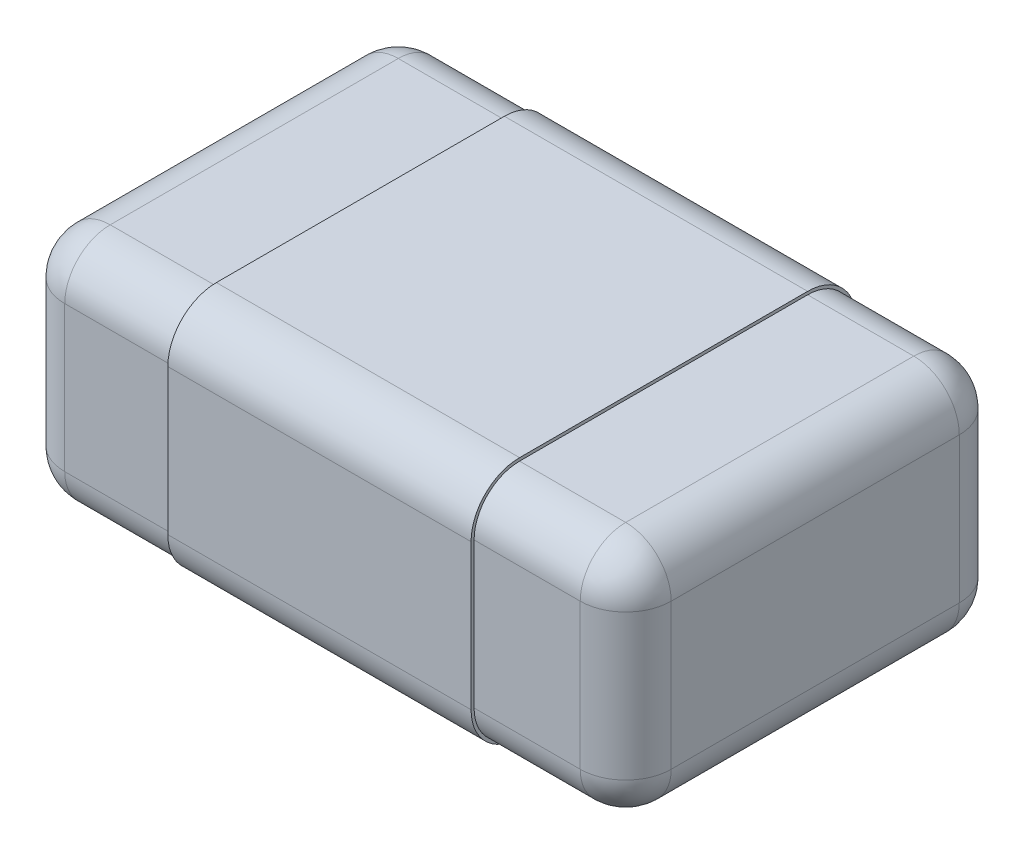
from build123d import *

# Parameters (mm, degrees)
ESBO_O1_W                     = 2
ESBO_O1_H                     = 1.25
RESSALTO_EXTRUS_O1_DEPTH      = 0.78
FILETE1_R                     = 0.15
RESSALTO_EXTRUS_O4_DEPTH      = 0.5
RESSALTO_EXTRUS_O4_DEPTH_BACK = 0.5
RESSALTO_EXTRUS_O5_DEPTH      = 0.02


with BuildPart() as part:
    # Esboço1 → Ressalto-extrusão1 (new body)
    with BuildSketch(Plane(origin=(0, 0, 0), x_dir=(1, 0, 0), z_dir=(0, 1, 0))):
        Rectangle(ESBO_O1_W, ESBO_O1_H)
    extrude(amount=-RESSALTO_EXTRUS_O1_DEPTH)

    # Filete1
    filete1_edges = [part.edges().sort_by_distance(p)[0] for p in [
        (1, -0.78, 0),
        (0, -0.78, -0.625),
        (-1, -0.78, 0),
        (0, 0, -0.625),
        (1, 0, 0),
        (0, 0, 0.625),
        (-1, 0, 0),
        (0, -0.78, 0.625),
        (-1, -0.39, -0.625),
        (1, -0.39, -0.625),
        (1, -0.39, 0.625),
        (-1, -0.39, 0.625),
    ]]
    fillet(filete1_edges, radius=FILETE1_R)

    # Esboço4 → Ressalto-extrusão4 (add, two sides)
    with BuildSketch(Plane(origin=(0, 0, 0), x_dir=(0, 0, -1), z_dir=(1, 0, 0))) as ressalto_extrus_o4_sk:
        with BuildLine():
            Line((0.635, -0.63), (0.635, -0.15))
            ThreePointArc((0.635, -0.15), (0.588137085, -0.036862915), (0.475, 0.01))
            Line((0.475, 0.01), (-0.475, 0.01))
            ThreePointArc((-0.475, 0.01), (-0.588137085, -0.036862915), (-0.635, -0.15))
            Line((-0.635, -0.15), (-0.635, -0.63))
            ThreePointArc((-0.635, -0.63), (-0.588137085, -0.743137085), (-0.475, -0.79))
            Line((-0.475, -0.79), (0.475, -0.79))
            ThreePointArc((0.475, -0.79), (0.588137085, -0.743137085), (0.635, -0.63))
        make_face()
        with BuildLine():
            Line((0.625, -0.63), (0.625, -0.15))
            ThreePointArc((0.625, -0.15), (0.581066017, -0.043933983), (0.475, 0))
            Line((0.475, 0), (-0.475, 0))
            ThreePointArc((-0.475, 0), (-0.581066017, -0.043933983), (-0.625, -0.15))
            Line((-0.625, -0.15), (-0.625, -0.63))
            ThreePointArc((-0.625, -0.63), (-0.581066017, -0.736066017), (-0.475, -0.78))
            Line((-0.475, -0.78), (0.475, -0.78))
            ThreePointArc((0.475, -0.78), (0.581066017, -0.736066017), (0.625, -0.63))
        make_face(mode=Mode.SUBTRACT)
    extrude(amount=RESSALTO_EXTRUS_O4_DEPTH)
    extrude(ressalto_extrus_o4_sk.sketch, amount=-RESSALTO_EXTRUS_O4_DEPTH_BACK)

    # Esboço2 → Ressalto-extrusão5 (add)
    with BuildSketch(Plane(origin=(0, -0.79, 0), x_dir=(0, 0, 1), z_dir=(0, -1, 0))):
        with BuildLine():
            Line((0.240411447, -0.215189873), (0.240411447, -0.462025316))
            Line((0.240411447, -0.462025316), (0.158330751, -0.462025316))
            add(Edge.make_bspline(
                [(0.158330751, -0.462025316), (0.152214367, -0.456963441), (0.140208237, -0.447027254), (0.12230397, -0.432732049), (0.104986645, -0.419110313), (0.088088852, -0.406373508), (0.071638652, -0.394418598), (0.055729879, -0.383059249), (0.04010761, -0.372628254), (0.02977976, -0.365986606), (0.024727112, -0.362737342)],
                knots=[0, 0, 0, 0, 1.143871494, 2.245357909, 3.300914739, 4.318253735, 5.293884102, 6.230829319, 7.13447631, 8, 8, 8, 8], degree=3))
            add(Edge.make_bspline(
                [(0.024727112, -0.362737342), (0.018467772, -0.358883426), (0.00649251, -0.351510179), (-0.011299949, -0.341907859), (-0.027841839, -0.333863461), (-0.043428254, -0.327364414), (-0.058501424, -0.322335856), (-0.073657737, -0.319037953), (-0.088968207, -0.316848981), (-0.099276497, -0.316586719), (-0.104426369, -0.316455696)],
                knots=[0, 0, 0, 0, 1.267768508, 2.425473269, 3.486024264, 4.439590646, 5.336903618, 6.222592004, 7.112032784, 8, 8, 8, 8], degree=3))
            add(Edge.make_bspline(
                [(-0.104426369, -0.316455696), (-0.109973533, -0.31661856), (-0.120442742, -0.316925935), (-0.135183808, -0.319395248), (-0.147862366, -0.3238687), (-0.158544157, -0.329955464), (-0.16699737, -0.337794162), (-0.172986786, -0.347194623), (-0.176714501, -0.357985485), (-0.177106684, -0.365673027), (-0.177310072, -0.36965981)],
                knots=[0, 0, 0, 0, 1.306909451, 2.466541577, 3.505869428, 4.459795217, 5.344572835, 6.193571478, 7.063180651, 8, 8, 8, 8], degree=3))
            add(Edge.make_bspline(
                [(-0.177310072, -0.36965981), (-0.177088445, -0.373873366), (-0.176649647, -0.382215733), (-0.172906717, -0.394304114), (-0.167362161, -0.405870143), (-0.162961227, -0.413368033), (-0.160696148, -0.417227057)],
                knots=[0, 0, 0, 0, 0.988472559, 1.957064427, 2.948539211, 4, 4, 4, 4], degree=3))
            add(Edge.make_bspline(
                [(-0.160696148, -0.417227057), (-0.158162705, -0.420841831), (-0.153335217, -0.427729798), (-0.14551733, -0.436518088), (-0.138585493, -0.443311015), (-0.134646389, -0.447447152), (-0.133006275, -0.449169304)],
                knots=[0, 0, 0, 0, 1.249878488, 2.381649198, 3.326171657, 4, 4, 4, 4], degree=3))
            Line((-0.133006275, -0.449169304), (-0.133006275, -0.455696203))
            Line((-0.133006275, -0.455696203), (-0.241293458, -0.455696203))
            add(Edge.make_bspline(
                [(-0.241293458, -0.455696203), (-0.243030602, -0.452991868), (-0.246833272, -0.447071984), (-0.251734635, -0.436649009), (-0.256834934, -0.424293195), (-0.26197876, -0.410355035), (-0.266458759, -0.395520181), (-0.269739252, -0.380513709), (-0.271805277, -0.365794466), (-0.272101339, -0.356051915), (-0.272246781, -0.351265823)],
                knots=[0, 0, 0, 0, 0.69970136, 1.531670699, 2.504079761, 3.612943238, 4.767349377, 5.877514774, 6.957315063, 8, 8, 8, 8], degree=3))
            add(Edge.make_bspline(
                [(-0.272246781, -0.351265823), (-0.272145838, -0.346348053), (-0.271949257, -0.336770977), (-0.270052265, -0.322880358), (-0.266883874, -0.309923425), (-0.262513205, -0.297885305), (-0.2570145, -0.286673475), (-0.24997581, -0.276546396), (-0.241814993, -0.267285593), (-0.232475839, -0.258916878), (-0.221906303, -0.251655604), (-0.21043315, -0.245154857), (-0.197820463, -0.239860807), (-0.184283525, -0.23536637), (-0.169658558, -0.232092503), (-0.154107163, -0.2296073), (-0.137518514, -0.228111727), (-0.126119876, -0.227937721), (-0.120249154, -0.227848101)],
                knots=[0, 0, 0, 0, 1.059873424, 2.064042983, 3.015596836, 3.930697506, 4.820695307, 5.699957467, 6.581199529, 7.477193696, 8.396013015, 9.341094634, 10.315416404, 11.340324501, 12.412707035, 13.542640562, 14.734368785, 16, 16, 16, 16], degree=3))
            add(Edge.make_bspline(
                [(-0.120249154, -0.227848101), (-0.112856677, -0.228016187), (-0.098089689, -0.22835195), (-0.076109458, -0.23116239), (-0.054324675, -0.235452453), (-0.032644635, -0.241809914), (-0.010659972, -0.250133389), (0.01194365, -0.260654571), (0.035218138, -0.273724386), (0.050657644, -0.283701701), (0.058647207, -0.288864715)],
                knots=[0, 0, 0, 0, 0.92383478, 1.845424201, 2.765944236, 3.697111989, 4.666093288, 5.70224482, 6.810968485, 8, 8, 8, 8], degree=3))
            add(Edge.make_bspline(
                [(0.058647207, -0.288864715), (0.063540545, -0.292239236), (0.073096713, -0.298829317), (0.086879374, -0.3088528), (0.099855338, -0.318723297), (0.111778424, -0.328382753), (0.122497499, -0.33725099), (0.13166194, -0.344970557), (0.139184524, -0.351253132), (0.143567164, -0.355051598), (0.145474738, -0.356704905)],
                knots=[0, 0, 0, 0, 1.293836837, 2.526725554, 3.709287413, 4.842241028, 5.866627263, 6.737584004, 7.450524958, 8, 8, 8, 8], degree=3))
            Line((0.145474738, -0.356704905), (0.145474738, -0.215189873))
            Line((0.145474738, -0.215189873), (0.240411447, -0.215189873))
        make_face()
        with BuildLine():
            add(Edge.make_bspline(
                [(-0.00988523, 0.120886076), (0.00066438, 0.120777596), (0.021112324, 0.120567332), (0.050770501, 0.119340622), (0.078415824, 0.117074446), (0.10401909, 0.113930641), (0.127675305, 0.11001546), (0.149219582, 0.104722524), (0.168857978, 0.09868919), (0.180855217, 0.093374077), (0.186613979, 0.090822785)],
                knots=[0, 0, 0, 0, 1.264448795, 2.450837183, 3.556883169, 4.58795224, 5.542121969, 6.428511603, 7.245674236, 8, 8, 8, 8], degree=3))
            add(Edge.make_bspline(
                [(0.186613979, 0.090822785), (0.191832724, 0.088116676), (0.201962475, 0.082864032), (0.215475974, 0.073081294), (0.227068062, 0.062211939), (0.236600164, 0.050031826), (0.243987269, 0.036453455), (0.249411672, 0.021580295), (0.252443019, 0.005204892), (0.252855826, -0.006145441), (0.253069675, -0.012025316)],
                knots=[0, 0, 0, 0, 1.083268664, 2.102659247, 3.066213605, 4.006517345, 4.942721993, 5.906487414, 6.915486013, 8, 8, 8, 8], degree=3))
            add(Edge.make_bspline(
                [(0.253069675, -0.012025316), (0.252852783, -0.017871645), (0.252432967, -0.029187831), (0.249431014, -0.045506204), (0.243963122, -0.060330616), (0.236600695, -0.073883764), (0.227031616, -0.0861274), (0.215297585, -0.09703571), (0.201515042, -0.106829225), (0.191236688, -0.112131567), (0.185921732, -0.114873418)],
                knots=[0, 0, 0, 0, 1.07440951, 2.079632991, 3.034098871, 3.966800755, 4.903586396, 5.876505587, 6.901937131, 8, 8, 8, 8], degree=3))
            add(Edge.make_bspline(
                [(0.185921732, -0.114873418), (0.180129026, -0.117422161), (0.168091236, -0.122718691), (0.148460723, -0.128771479), (0.127002925, -0.134018254), (0.103578021, -0.138143353), (0.078175642, -0.141083229), (0.050772622, -0.143405159), (0.021276728, -0.144615824), (0.000927931, -0.144827376), (-0.009588553, -0.144936709)],
                knots=[0, 0, 0, 0, 0.761707614, 1.582900397, 2.469804074, 3.421542703, 4.445391707, 5.54897881, 6.73328501, 8, 8, 8, 8], degree=3))
            add(Edge.make_bspline(
                [(-0.009588553, -0.144936709), (-0.020369762, -0.144887229), (-0.041117875, -0.144792007), (-0.071028581, -0.143333759), (-0.098482372, -0.1412524), (-0.123614463, -0.13823957), (-0.146683241, -0.134109276), (-0.167944168, -0.128750561), (-0.187668818, -0.122481979), (-0.199867758, -0.117027457), (-0.205791085, -0.114378956)],
                knots=[0, 0, 0, 0, 1.292793539, 2.487942473, 3.590368342, 4.594084519, 5.522245339, 6.398581889, 7.222414246, 8, 8, 8, 8], degree=3))
            add(Edge.make_bspline(
                [(-0.205791085, -0.114378956), (-0.211110301, -0.111609007), (-0.221376966, -0.106262704), (-0.235073612, -0.096336734), (-0.246722638, -0.085334478), (-0.256127396, -0.072993755), (-0.263517384, -0.059482581), (-0.268421711, -0.044656959), (-0.271798667, -0.028757919), (-0.272094432, -0.017714037), (-0.272246781, -0.012025316)],
                knots=[0, 0, 0, 0, 1.109275554, 2.141022398, 3.121040764, 4.065986229, 5.002793741, 5.958326063, 6.948330593, 8, 8, 8, 8], degree=3))
            add(Edge.make_bspline(
                [(-0.272246781, -0.012025316), (-0.272046579, -0.006043877), (-0.271660816, 0.005481624), (-0.268470632, 0.021993085), (-0.263150324, 0.036960304), (-0.255454148, 0.050345773), (-0.245642566, 0.062390805), (-0.233819981, 0.0732678), (-0.219846704, 0.08298967), (-0.209487785, 0.0882761), (-0.204109914, 0.09102057)],
                knots=[0, 0, 0, 0, 1.090787275, 2.10181366, 3.055147114, 3.976595958, 4.904774509, 5.879576888, 6.899174391, 8, 8, 8, 8], degree=3))
            add(Edge.make_bspline(
                [(-0.204109914, 0.09102057), (-0.198282864, 0.093565617), (-0.186203782, 0.098841329), (-0.166564535, 0.104939577), (-0.145056829, 0.110083568), (-0.121581167, 0.114013891), (-0.096247041, 0.117211018), (-0.069048851, 0.119254133), (-0.040063859, 0.120736953), (-0.020139192, 0.120835408), (-0.00988523, 0.120886076)],
                knots=[0, 0, 0, 0, 0.770502262, 1.59719915, 2.489107463, 3.450471223, 4.48167079, 5.584362407, 6.7568247, 8, 8, 8, 8], degree=3))
        make_face()
        with BuildLine():
            add(Edge.make_bspline(
                [(-0.00988523, 0.032278481), (-0.017335235, 0.032224744), (-0.03164288, 0.032121543), (-0.052217355, 0.031779129), (-0.07104871, 0.031022732), (-0.088152315, 0.029776962), (-0.103569772, 0.028501522), (-0.117255137, 0.026701021), (-0.129212067, 0.024681932), (-0.139562429, 0.02231793), (-0.148443418, 0.019579571), (-0.156053558, 0.016386943), (-0.162575373, 0.012891542), (-0.167915103, 0.008780082), (-0.172136864, 0.004265744), (-0.175104817, -0.00076613), (-0.176997981, -0.00622262), (-0.177204629, -0.010064822), (-0.177310072, -0.012025316)],
                knots=[0, 0, 0, 0, 1.929100326, 3.704814234, 5.327997663, 6.808188623, 8.145079156, 9.332956936, 10.381192375, 11.283900527, 12.080268448, 12.784124463, 13.418341996, 13.990284721, 14.521958489, 15.007958048, 15.493807677, 16, 16, 16, 16], degree=3))
            add(Edge.make_bspline(
                [(-0.177310072, -0.012025316), (-0.177201487, -0.013952383), (-0.176986902, -0.017760626), (-0.175104835, -0.023185486), (-0.172136995, -0.028217841), (-0.167914478, -0.032730347), (-0.162578032, -0.036849502), (-0.156030446, -0.040317584), (-0.148470728, -0.043661172), (-0.139557656, -0.046357536), (-0.129213554, -0.048735481), (-0.117222845, -0.050759578), (-0.103502855, -0.052543669), (-0.088020951, -0.053833617), (-0.0708179, -0.05507521), (-0.051854642, -0.055827566), (-0.031148424, -0.056172575), (-0.016774848, -0.05627552), (-0.009291876, -0.056329114)],
                knots=[0, 0, 0, 0, 0.496275509, 0.980733238, 1.465340469, 1.995491057, 2.565795237, 3.198195815, 3.903381773, 4.697468199, 5.597590203, 6.642822578, 7.835737307, 9.168797815, 10.653238981, 12.288779388, 14.067915585, 16, 16, 16, 16], degree=3))
            add(Edge.make_bspline(
                [(-0.009291876, -0.056329114), (-0.001973728, -0.056275178), (0.012136138, -0.056171186), (0.03247988, -0.05582839), (0.051179383, -0.055073158), (0.068184397, -0.053829711), (0.083534738, -0.052544366), (0.097188903, -0.050756791), (0.109205617, -0.048707271), (0.119659211, -0.04637592), (0.128722094, -0.043638718), (0.136452147, -0.040314019), (0.143172519, -0.036869708), (0.148638271, -0.03276527), (0.152840617, -0.028184778), (0.155947608, -0.023217447), (0.157803261, -0.017756603), (0.158022185, -0.013951031), (0.158132966, -0.012025316)],
                knots=[0, 0, 0, 0, 1.896767928, 3.657092201, 5.27328851, 6.746368892, 8.076025924, 9.26503724, 10.314272961, 11.23449221, 12.039773993, 12.763366423, 13.413189726, 13.992459479, 14.524640598, 15.015510453, 15.501823705, 16, 16, 16, 16], degree=3))
            add(Edge.make_bspline(
                [(0.158132966, -0.012025316), (0.15802208, -0.010099752), (0.15780295, -0.006294478), (0.155948822, -0.000831439), (0.152835849, 0.004127284), (0.148671843, 0.008728943), (0.143106752, 0.012682069), (0.136512584, 0.016318615), (0.128687955, 0.01944403), (0.119667636, 0.022250216), (0.109191238, 0.024514546), (0.097179523, 0.026795554), (0.083416992, 0.028298466), (0.068000477, 0.029876176), (0.050905713, 0.030829761), (0.032154994, 0.031837726), (0.011706673, 0.032104279), (-0.002501472, 0.032218909), (-0.00988523, 0.032278481)],
                knots=[0, 0, 0, 0, 0.496691071, 0.981554468, 1.470960882, 2.001555398, 2.573987342, 3.225948283, 3.944107278, 4.746988257, 5.664464036, 6.712061857, 7.904911462, 9.239876577, 10.716497891, 12.328258503, 14.091851269, 16, 16, 16, 16], degree=3))
        make_face(mode=Mode.SUBTRACT)
        with BuildLine():
            add(Edge.make_bspline(
                [(0.091083915, 0.450632911), (0.097053447, 0.450509358), (0.108785804, 0.450266531), (0.125962302, 0.448646824), (0.142305783, 0.445603054), (0.157799263, 0.44161447), (0.172377919, 0.436489934), (0.185869221, 0.430263312), (0.198287496, 0.422964234), (0.205694588, 0.417127981), (0.209359232, 0.414240506)],
                knots=[0, 0, 0, 0, 1.134951389, 2.230602796, 3.275446553, 4.29236384, 5.269554879, 6.208874539, 7.113844281, 8, 8, 8, 8], degree=3))
            add(Edge.make_bspline(
                [(0.209359232, 0.414240506), (0.2127705, 0.411189439), (0.219533431, 0.405140616), (0.228167833, 0.394717509), (0.23582354, 0.383703866), (0.242077724, 0.371707746), (0.247123043, 0.358665047), (0.25063184, 0.344347483), (0.252704345, 0.32872668), (0.25294503, 0.317892958), (0.253069675, 0.312282437)],
                knots=[0, 0, 0, 0, 0.955266016, 1.893840718, 2.820634586, 3.754367388, 4.713946363, 5.736548792, 6.827813699, 8, 8, 8, 8], degree=3))
            add(Edge.make_bspline(
                [(0.253069675, 0.312282437), (0.252962149, 0.305883194), (0.252754409, 0.293519747), (0.250987221, 0.275656885), (0.247970503, 0.259169723), (0.243671666, 0.244172636), (0.23869952, 0.230568383), (0.233326183, 0.218330164), (0.227914993, 0.207265708), (0.223722107, 0.20063384), (0.221720782, 0.197468354)],
                knots=[0, 0, 0, 0, 1.271933853, 2.45739788, 3.56403977, 4.599221435, 5.554937142, 6.441247417, 7.255985077, 8, 8, 8, 8], degree=3))
            Line((0.221720782, 0.197468354), (0.113829169, 0.197468354))
            Line((0.113829169, 0.197468354), (0.113829169, 0.205874209))
            add(Edge.make_bspline(
                [(0.113829169, 0.205874209), (0.116773443, 0.209066417), (0.122695825, 0.215487517), (0.130869901, 0.225919795), (0.138193223, 0.237268836), (0.145102081, 0.248979277), (0.150773289, 0.260947818), (0.154979882, 0.272618529), (0.157655172, 0.283812355), (0.157977308, 0.291139201), (0.158132966, 0.294679589)],
                knots=[0, 0, 0, 0, 1.028515649, 2.068850487, 3.134434502, 4.226024606, 5.287939915, 6.266010027, 7.162122652, 8, 8, 8, 8], degree=3))
            add(Edge.make_bspline(
                [(0.158132966, 0.294679589), (0.157967363, 0.298909235), (0.157619397, 0.307796623), (0.155525141, 0.318921878), (0.153055031, 0.328005688), (0.149838156, 0.334308479), (0.14592635, 0.340209222), (0.142479798, 0.343461546), (0.140727903, 0.345114715)],
                knots=[0, 0, 0, 0, 1.383822774, 2.907706505, 3.696267359, 4.453880301, 5.214101212, 6, 6, 6, 6], degree=3))
            add(Edge.make_bspline(
                [(0.140727903, 0.345114715), (0.137650114, 0.347558836), (0.131257704, 0.352635149), (0.121545824, 0.356910215), (0.112632122, 0.359733982), (0.104401993, 0.360968757), (0.094929568, 0.361895895), (0.088153276, 0.361980445), (0.084557017, 0.362025316)],
                knots=[0, 0, 0, 0, 1.17336722, 2.437023599, 3.149324183, 3.970868836, 4.92311568, 6, 6, 6, 6], degree=3))
            add(Edge.make_bspline(
                [(0.084557017, 0.362025316), (0.081027018, 0.361955452), (0.074372913, 0.361823756), (0.065002919, 0.360702671), (0.056936311, 0.358631198), (0.050052002, 0.355875338), (0.044329839, 0.352346183), (0.039527085, 0.348302991), (0.035324556, 0.343888435), (0.033332401, 0.34041422), (0.032341827, 0.338686709)],
                knots=[0, 0, 0, 0, 1.405388907, 2.649180623, 3.747479513, 4.712702894, 5.590628025, 6.410723464, 7.209751833, 8, 8, 8, 8], degree=3))
            add(Edge.make_bspline(
                [(0.032341827, 0.338686709), (0.03142998, 0.336863083), (0.029574546, 0.333152355), (0.027770405, 0.327028188), (0.026453486, 0.320442524), (0.025676926, 0.311242073), (0.025409984, 0.300187215), (0.0252816, 0.291515122), (0.025221574, 0.287460443)],
                knots=[0, 0, 0, 0, 0.701148582, 1.426703207, 2.190614458, 3.012117132, 4.603000887, 6, 6, 6, 6], degree=3))
            Line((0.025221574, 0.287460443), (0.025221574, 0.273417722))
            Line((0.025221574, 0.273417722), (-0.063386021, 0.273417722))
            Line((-0.063386021, 0.273417722), (-0.063386021, 0.286669304))
            add(Edge.make_bspline(
                [(-0.063386021, 0.286669304), (-0.063455272, 0.291589096), (-0.063587726, 0.300999093), (-0.065283585, 0.314379314), (-0.068038724, 0.326548177), (-0.072048081, 0.333352491), (-0.073967509, 0.336609968)],
                knots=[0, 0, 0, 0, 1.139338921, 2.179193021, 3.128312282, 4, 4, 4, 4], degree=3))
            add(Edge.make_bspline(
                [(-0.073967509, 0.336609968), (-0.075144604, 0.338067341), (-0.077528059, 0.341018318), (-0.081972659, 0.3447793), (-0.087045131, 0.348023411), (-0.092781122, 0.350879523), (-0.099410871, 0.353029019), (-0.107036227, 0.354586808), (-0.115707438, 0.355573854), (-0.121861529, 0.355654062), (-0.125094882, 0.355696203)],
                knots=[0, 0, 0, 0, 0.792054515, 1.603800977, 2.451955997, 3.338654888, 4.310024996, 5.394433015, 6.631037583, 8, 8, 8, 8], degree=3))
            add(Edge.make_bspline(
                [(-0.125094882, 0.355696203), (-0.127636319, 0.355646326), (-0.132472698, 0.355551411), (-0.139363003, 0.354651034), (-0.145554029, 0.353210268), (-0.152540212, 0.350499658), (-0.160016751, 0.346296122), (-0.164576318, 0.341597066), (-0.166728585, 0.339378956)],
                knots=[0, 0, 0, 0, 0.989765321, 1.883532761, 2.702857336, 3.459039476, 4.800582506, 6, 6, 6, 6], degree=3))
            add(Edge.make_bspline(
                [(-0.166728585, 0.339378956), (-0.168629059, 0.336520165), (-0.172496417, 0.330702685), (-0.175401011, 0.320710601), (-0.176946736, 0.311148559), (-0.177196151, 0.305002588), (-0.177310072, 0.302195411)],
                knots=[0, 0, 0, 0, 1.043133073, 2.122717367, 3.142549896, 4, 4, 4, 4], degree=3))
            add(Edge.make_bspline(
                [(-0.177310072, 0.302195411), (-0.17706029, 0.298020075), (-0.176549144, 0.28947581), (-0.172961809, 0.276812285), (-0.167689707, 0.264345965), (-0.163303624, 0.256308201), (-0.161091718, 0.252254747)],
                knots=[0, 0, 0, 0, 0.943448275, 1.930640289, 2.956419505, 4, 4, 4, 4], degree=3))
            add(Edge.make_bspline(
                [(-0.161091718, 0.252254747), (-0.159009143, 0.249014008), (-0.154592346, 0.242140936), (-0.147988434, 0.234195188), (-0.142547416, 0.227951297), (-0.138771149, 0.223901281), (-0.135817999, 0.220310799), (-0.133873197, 0.218259931), (-0.133006275, 0.217345728)],
                knots=[0, 0, 0, 0, 1.543909965, 3.274378284, 4.136373371, 4.866604337, 5.494772765, 6, 6, 6, 6], degree=3))
            Line((-0.133006275, 0.217345728), (-0.133006275, 0.210126582))
            Line((-0.133006275, 0.210126582), (-0.240601211, 0.210126582))
            add(Edge.make_bspline(
                [(-0.240601211, 0.210126582), (-0.242450585, 0.213303994), (-0.246369384, 0.220036887), (-0.251809205, 0.23114714), (-0.25692918, 0.243865818), (-0.262215608, 0.257716956), (-0.26656988, 0.27251795), (-0.269916096, 0.2877018), (-0.271795048, 0.303104175), (-0.272095885, 0.313431485), (-0.272246781, 0.318611551)],
                knots=[0, 0, 0, 0, 0.771891608, 1.635628057, 2.594636255, 3.650327867, 4.747660996, 5.83112928, 6.912118025, 8, 8, 8, 8], degree=3))
            add(Edge.make_bspline(
                [(-0.272246781, 0.318611551), (-0.272162928, 0.323527912), (-0.272000999, 0.333021924), (-0.270450242, 0.346734122), (-0.26817752, 0.359473677), (-0.264691988, 0.371234892), (-0.260176084, 0.382048398), (-0.254988939, 0.392133686), (-0.248714576, 0.401286718), (-0.243888001, 0.40677054), (-0.241491243, 0.409493671)],
                knots=[0, 0, 0, 0, 1.199045861, 2.315484163, 3.362897413, 4.352810628, 5.301242744, 6.218611169, 7.11540602, 8, 8, 8, 8], degree=3))
            add(Edge.make_bspline(
                [(-0.241491243, 0.409493671), (-0.238696899, 0.412313667), (-0.233108984, 0.417952879), (-0.22327782, 0.424990816), (-0.212499908, 0.43108311), (-0.200543554, 0.435818114), (-0.187767102, 0.439761209), (-0.174090153, 0.442290823), (-0.15968961, 0.444099424), (-0.149824126, 0.444234605), (-0.144774471, 0.444303797)],
                knots=[0, 0, 0, 0, 0.899477092, 1.798705297, 2.733090891, 3.702715351, 4.710848355, 5.762743087, 6.854858352, 8, 8, 8, 8], degree=3))
            add(Edge.make_bspline(
                [(-0.144774471, 0.444303797), (-0.13774026, 0.44410545), (-0.124053298, 0.443719512), (-0.104205466, 0.440419218), (-0.085723176, 0.434865413), (-0.071472445, 0.428381022), (-0.060961816, 0.422356634), (-0.053920927, 0.417330456), (-0.047479686, 0.412149259), (-0.041765251, 0.406592552), (-0.036904716, 0.400565547), (-0.032634834, 0.394283254), (-0.029107381, 0.387581547), (-0.027371347, 0.382880184), (-0.026499154, 0.380518196)],
                knots=[0, 0, 0, 0, 1.770401226, 3.444794915, 5.049233062, 6.61689752, 7.37571781, 8.096540093, 8.792709469, 9.455985318, 10.099006896, 10.739021174, 11.366478004, 12, 12, 12, 12], degree=3))
            Line((-0.026499154, 0.380518196), (-0.021752319, 0.380518196))
            add(Edge.make_bspline(
                [(-0.021752319, 0.380518196), (-0.020681286, 0.384576743), (-0.018514064, 0.392789164), (-0.013959303, 0.402638269), (-0.008981778, 0.410192744), (-0.004345557, 0.415989843), (0.001501742, 0.421512344), (0.005845282, 0.424986086), (0.008113188, 0.426799842)],
                knots=[0, 0, 0, 0, 1.338731653, 2.708907517, 3.438678351, 4.224363953, 5.072881742, 6, 6, 6, 6], degree=3))
            add(Edge.make_bspline(
                [(0.008113188, 0.426799842), (0.010417283, 0.428504318), (0.015179942, 0.432027539), (0.023289496, 0.436373299), (0.032211654, 0.440482325), (0.042109731, 0.443996484), (0.052959889, 0.447020881), (0.064808968, 0.449142306), (0.077637915, 0.450450203), (0.086498549, 0.450570604), (0.091083915, 0.450632911)],
                knots=[0, 0, 0, 0, 0.781940693, 1.616303212, 2.506838174, 3.463859656, 4.481845554, 5.580393902, 6.747857106, 8, 8, 8, 8], degree=3))
        make_face()
    extrude(amount=RESSALTO_EXTRUS_O5_DEPTH)


solid = part.part
